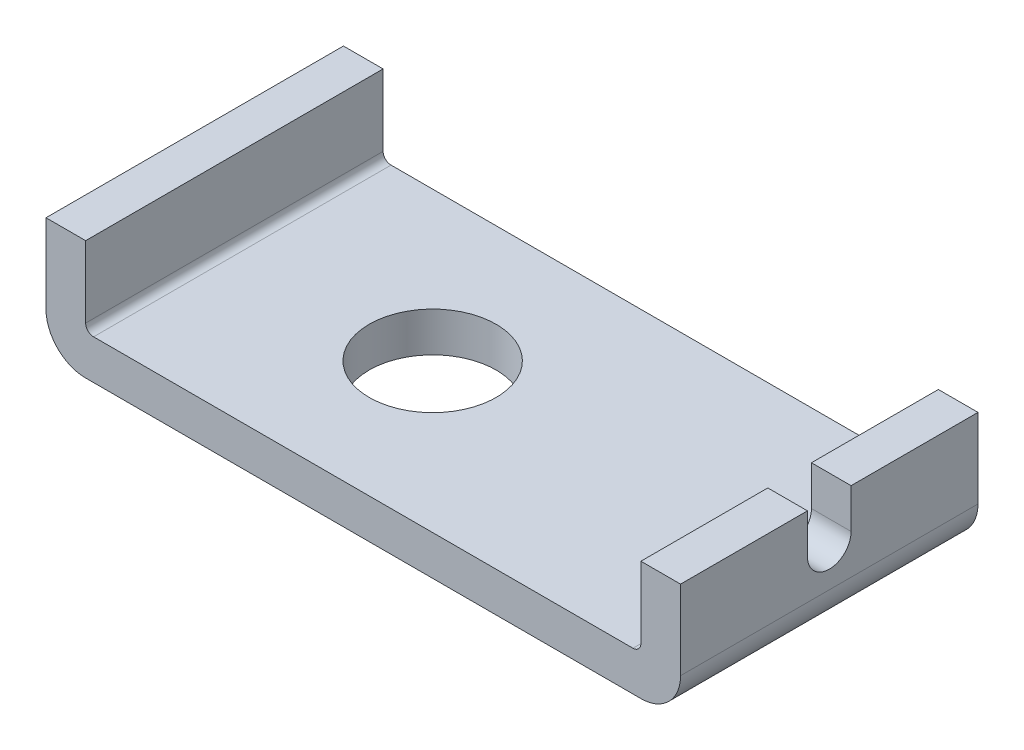
from build123d import *

# Parameters (mm, degrees)
BOSS_EXTRUDE1_DEPTH = 37.5
CUT_EXTRUDE1_DEPTH  = 10
SKETCH5_R           = 16
CUT_EXTRUDE4_DEPTH  = 11


with BuildPart() as part:
    # Sketch1 → Boss-Extrude1 (new body, symmetric)
    with BuildSketch(Plane.XY):
        with BuildLine():
            Line((-91.516709512, 34.755784062), (-81.516709512, 34.755784062))
            Line((-81.516709512, 34.755784062), (-81.516709512, 16.755784062))
            ThreePointArc((-81.516709512, 16.755784062), (-80.930923074, 15.341570499), (-79.516709512, 14.755784062))
            Line((-79.516709512, 14.755784062), (56.483290488, 14.755784062))
            ThreePointArc((56.483290488, 14.755784062), (57.897504051, 15.341570499), (58.483290488, 16.755784062))
            Line((58.483290488, 16.755784062), (58.483290488, 34.755784062))
            Line((58.483290488, 34.755784062), (68.483290488, 34.755784062))
            Line((68.483290488, 34.755784062), (68.483290488, 14.755784062))
            ThreePointArc((68.483290488, 14.755784062), (65.5543583, 7.68471625), (58.483290488, 4.755784062))
            Line((58.483290488, 4.755784062), (-81.516709512, 4.755784062))
            ThreePointArc((-81.516709512, 4.755784062), (-88.587777323, 7.68471625), (-91.516709512, 14.755784062))
            Line((-91.516709512, 14.755784062), (-91.516709512, 34.755784062))
        make_face()
    extrude(amount=BOSS_EXTRUDE1_DEPTH, both=True)

    # Sketch2 → Cut-Extrude1 (cut)
    with BuildSketch(Plane(origin=(68.483290488, 0, 0), x_dir=(0, 0, -1), z_dir=(1, 0, 0))):
        with BuildLine():
            Line((-5.5, 24.755784062), (-5.5, 34.755784062))
            Line((-5.5, 34.755784062), (5.5, 34.755784062))
            Line((5.5, 34.755784062), (5.5, 24.755784062))
            ThreePointArc((5.5, 24.755784062), (0, 19.255784062), (-5.5, 24.755784062))
        make_face()
    extrude(amount=-CUT_EXTRUDE1_DEPTH, mode=Mode.SUBTRACT)

    # Sketch5 → Cut-Extrude4 (cut, through all)
    with BuildSketch(Plane(origin=(0, 14.755784062, 0), x_dir=(1, 0, 0), z_dir=(0, 1, 0))):
        with Locations((-31.516709512, 0)):
            Circle(SKETCH5_R)
    extrude(amount=-CUT_EXTRUDE4_DEPTH, mode=Mode.SUBTRACT)


solid = part.part
